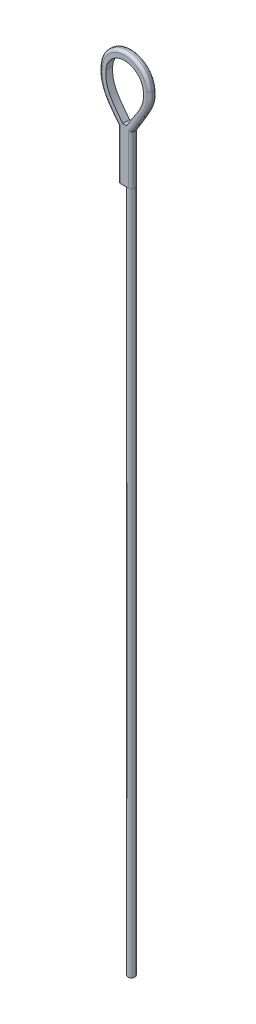
from build123d import *

# Parameters (mm, degrees)
SKETCH1_R                = 0.635
BOSS_EXTRUDE1_DEPTH      = 127
BOSS_EXTRUDE2_DEPTH      = 0.635
BOSS_EXTRUDE2_DEPTH_BACK = 0.635
FILLET1_R                = 0.508


with BuildPart() as part:
    # Sketch1 → Boss-Extrude1 (new body)
    with BuildSketch(Plane(origin=(0, 0, 0), x_dir=(1, 0, 0), z_dir=(0, 1, 0))):
        Circle(SKETCH1_R)
    extrude(amount=BOSS_EXTRUDE1_DEPTH)

    # Sketch2 → Boss-Extrude2 (add, two sides)
    with BuildSketch(Plane.XY) as boss_extrude2_sk:
        with BuildLine():
            Line((-1.905, 127), (0.635, 127))
            Line((0.635, 127), (0.635, 136.158420865))
            add(Edge.make_bspline(
                [(0.635, 136.158420865), (4.153630903, 141.818791199), (4.114669439, 141.992054971), (4.005734255, 144.307253859)],
                knots=[0, 0, 0, 0, 1, 1, 1, 1], degree=3))
            ThreePointArc((4.005734255, 144.307253859), (-0.739604915, 148.557439765), (-5.289336973, 144.098486718))
            add(Edge.make_bspline(
                [(-1.905, 136.158420865), (-3.718327637, 138.500370735), (-5.598593588, 140.574024695), (-5.289336973, 144.098486718)],
                knots=[0, 0, 0, 0, 1, 1, 1, 1], degree=3))
            Line((-1.905, 136.158420865), (-1.905, 127))
        make_face()
        with BuildLine():
            add(Edge.make_bspline(
                [(-0.297199842, 136.880205631), (-0.107641201, 137.223242161), (0.313462848, 137.90543324), (1.149179042, 139.110045469), (1.915323622, 140.205619235), (2.462394721, 141.272158502), (2.748069771, 142.085078064), (2.871045761, 142.816900596), (2.888508164, 143.458131128), (2.864325917, 143.820492805), (2.844879762, 143.995433072)],
                knots=[0, 0, 0, 0, 0.125, 0.25, 0.5, 0.625, 0.75, 0.875, 0.9375, 1, 1, 1, 1], degree=3))
            Line((-0.297199842, 136.880205631), (-0.972800158, 136.880205631))
            add(Edge.make_bspline(
                [(-0.972800158, 136.880205631), (-1.198644094, 137.171887712), (-1.663408729, 137.76102171), (-2.517671044, 138.87030936), (-3.240026875, 139.952731811), (-3.749328451, 141.06606592), (-4.016349262, 141.942088489), (-4.13205868, 142.739298518), (-4.150496215, 143.42980398), (-4.131124798, 143.810295526), (-4.114879762, 143.995433072)],
                knots=[0, 0, 0, 0, 0.125, 0.25, 0.5, 0.625, 0.75, 0.875, 0.9375, 1, 1, 1, 1], degree=3))
            ThreePointArc((-4.114879762, 143.995433072), (-0.635, 147.191296776), (2.844879762, 143.995433072))
        make_face(mode=Mode.SUBTRACT)
    extrude(amount=BOSS_EXTRUDE2_DEPTH)
    extrude(boss_extrude2_sk.sketch, amount=-BOSS_EXTRUDE2_DEPTH_BACK)

    # Fillet1
    fillet1_edges = [part.edges().sort_by_distance(p)[0] for p in [
        (-0.739604915, 148.557439765, -0.635),
        (0.635, 131.579210433, 0.635),
        (-0.739604915, 148.557439765, 0.635),
        (-1.905, 131.579210433, -0.635),
        (-1.905, 131.579210433, 0.635),
        (0.635, 131.579210433, -0.635),
    ]]
    fillet(fillet1_edges, radius=FILLET1_R)


solid = part.part
